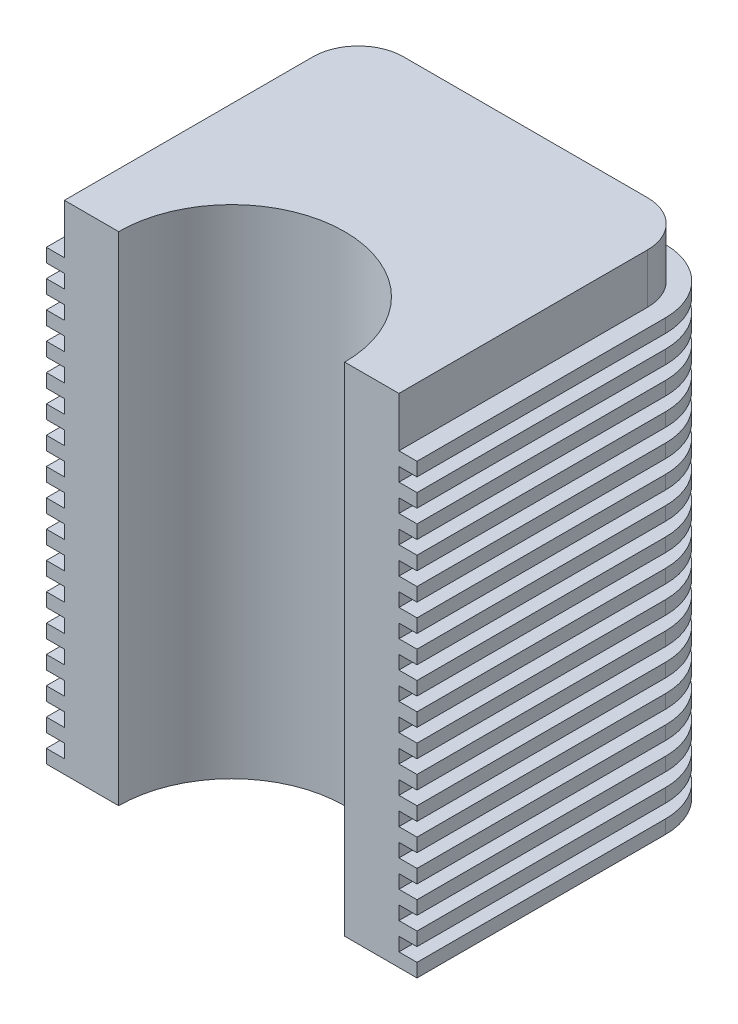
from build123d import *

# Parameters (mm, degrees)
BOSS_EXTRUDE1_DEPTH = 110
BOSS_EXTRUDE2_DEPTH = 3
LPATTERN2_COUNT     = 17
LPATTERN2_PITCH     = 6


with BuildPart() as part:
    # Sketch2 → Boss-Extrude1 (new body)
    with BuildSketch(Plane(origin=(0, 0, 0), x_dir=(1, 0, 0), z_dir=(0, 1, 0))):
        with BuildLine():
            Line((25, 0), (37, 0))
            Line((37, 0), (37, 55))
            ThreePointArc((37, 55), (34.071067812, 62.071067812), (27, 65))
            Line((27, 65), (-27, 65))
            ThreePointArc((-27, 65), (-34.071067812, 62.071067812), (-37, 55))
            Line((-37, 55), (-37, 0))
            Line((-37, 0), (-25, 0))
            ThreePointArc((-25, 0), (0, 25), (25, 0))
        make_face()
    extrude(amount=BOSS_EXTRUDE1_DEPTH)

    # Sketch3 → Boss-Extrude2 (add)
    with BuildSketch(Plane.XZ):
        with BuildLine():
            Line((-41, 0), (-41, -55))
            ThreePointArc((-41, -55), (-36.899494937, -64.899494937), (-27, -69))
            Line((-27, -69), (27, -69))
            ThreePointArc((27, -69), (36.899494937, -64.899494937), (41, -55))
            Line((41, -55), (41, 0))
            Line((41, 0), (37, 0))
            Line((37, 0), (37, -55))
            ThreePointArc((37, -55), (34.071067812, -62.071067812), (27, -65))
            Line((27, -65), (-27, -65))
            ThreePointArc((-27, -65), (-34.071067812, -62.071067812), (-37, -55))
            Line((-37, -55), (-37, 0))
            Line((-37, 0), (-41, 0))
        make_face()
    boss_extrude2 = extrude(amount=-BOSS_EXTRUDE2_DEPTH)

    # LPattern2: Boss-Extrude2 ×17
    with Locations(*[(0, i * LPATTERN2_PITCH, 0) for i in range(1, LPATTERN2_COUNT)]):
        add(boss_extrude2)


solid = part.part
